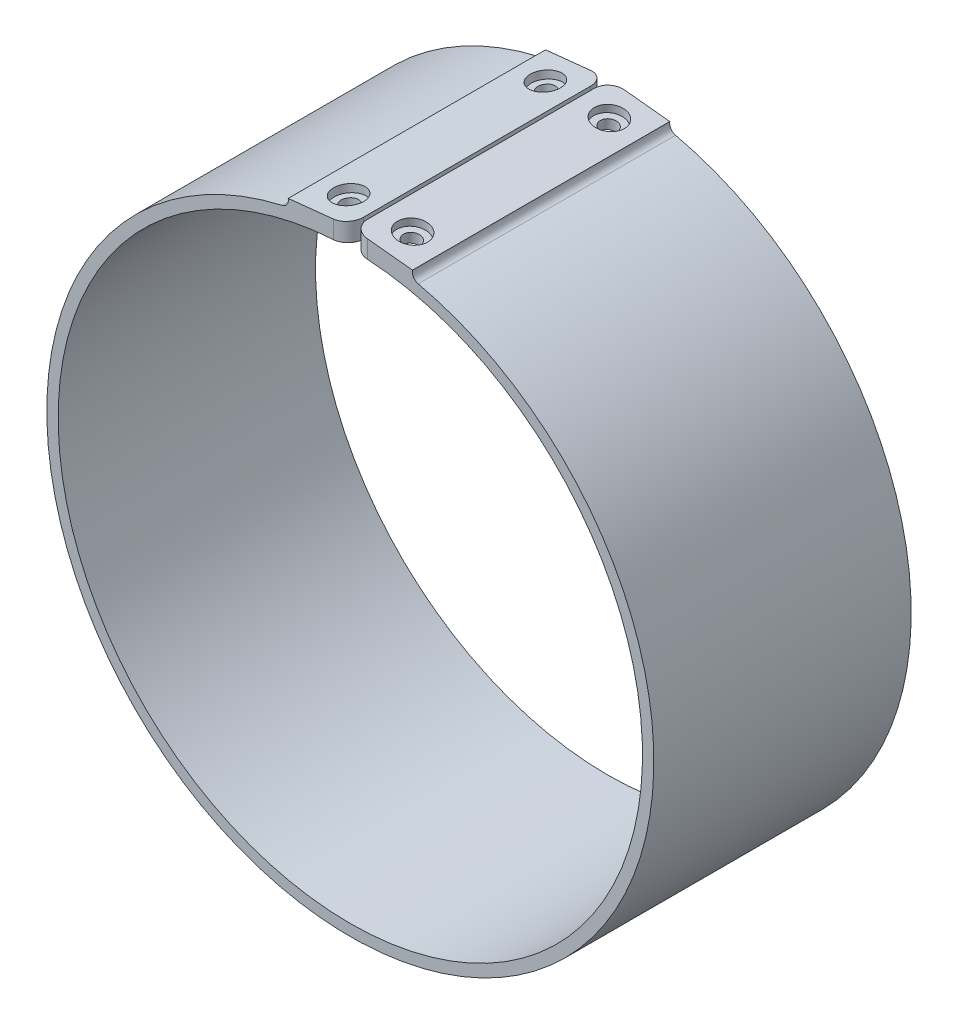
from build123d import *

# Parameters (mm, degrees)
BOSS_EXTRUDE1_DEPTH = 34
CUT_EXTRUDE2_START  = -2.320517
SKETCH3_R           = 1.1
CUT_EXTRUDE2_DEPTH  = 2.320517
SKETCH4_R           = 2
CUT_EXTRUDE3_DEPTH  = 1
FILLET1_R           = 2


with BuildPart() as part:
    # Sketch1 → Boss-Extrude1 (new body)
    with BuildSketch(Plane.XY):
        with BuildLine():
            Line((0.25, 38.599190406), (0.25, 41.099190406))
            Line((0.25, 41.099190406), (8.207138981, 40.272184219))
            ThreePointArc((8.207138981, 40.272184219), (8.347930101, 39.521941532), (8.972631806, 39.083268523))
            ThreePointArc((8.972631806, 39.083268523), (0, -40.1), (-8.972631806, 39.083268523))
            ThreePointArc((-8.972631806, 39.083268523), (-8.347930101, 39.521941532), (-8.207138981, 40.272184219))
            Line((-8.207138981, 40.272184219), (-0.25, 41.099190406))
            Line((-0.25, 41.099190406), (-0.25, 38.599190406))
            ThreePointArc((-0.25, 38.599190406), (0, -38.6), (0.25, 38.599190406))
        make_face()
    extrude(amount=BOSS_EXTRUDE1_DEPTH)

    # Sketch3 → Cut-Extrude2 (cut)
    with BuildSketch(Plane(origin=(-4.228569491, 40.685687313, 0), x_dir=(0.994642373, 0.103375773, 0), z_dir=(-0.103375773, 0.994642373, 0)).offset(CUT_EXTRUDE2_START)):
        with Locations((0, -4)):
            Circle(SKETCH3_R)
        with Locations((0, -30)):
            Circle(SKETCH3_R)
    cut_extrude2 = extrude(amount=CUT_EXTRUDE2_DEPTH, mode=Mode.SUBTRACT)

    # Sketch4 → Cut-Extrude3 (cut)
    with BuildSketch(Plane(origin=(-4.228569491, 40.685687313, 0), x_dir=(0.994642373, 0.103375773, 0), z_dir=(-0.103375773, 0.994642373, 0))):
        with Locations((0, -4)):
            Circle(SKETCH4_R)
        with Locations((0, -30)):
            Circle(SKETCH4_R)
    cut_extrude3 = extrude(amount=-CUT_EXTRUDE3_DEPTH, mode=Mode.SUBTRACT)

    # Mirror3: Cut-Extrude2, Cut-Extrude3 across plane
    add(cut_extrude2.mirror(Plane(origin=(0, 0, 0), x_dir=(0, 0, 1), z_dir=(1, 0, 0))), mode=Mode.SUBTRACT)
    add(cut_extrude3.mirror(Plane(origin=(0, 0, 0), x_dir=(0, 0, 1), z_dir=(1, 0, 0))), mode=Mode.SUBTRACT)

    # Fillet1
    fillet1_edges = [part.edges().sort_by_distance(p)[0] for p in [
        (-0.25, 39.849190406, 0),
        (0.25, 39.849190406, 34),
        (0.25, 39.849190406, 0),
        (-0.25, 39.849190406, 34),
    ]]
    fillet(fillet1_edges, radius=FILLET1_R)


solid = part.part
